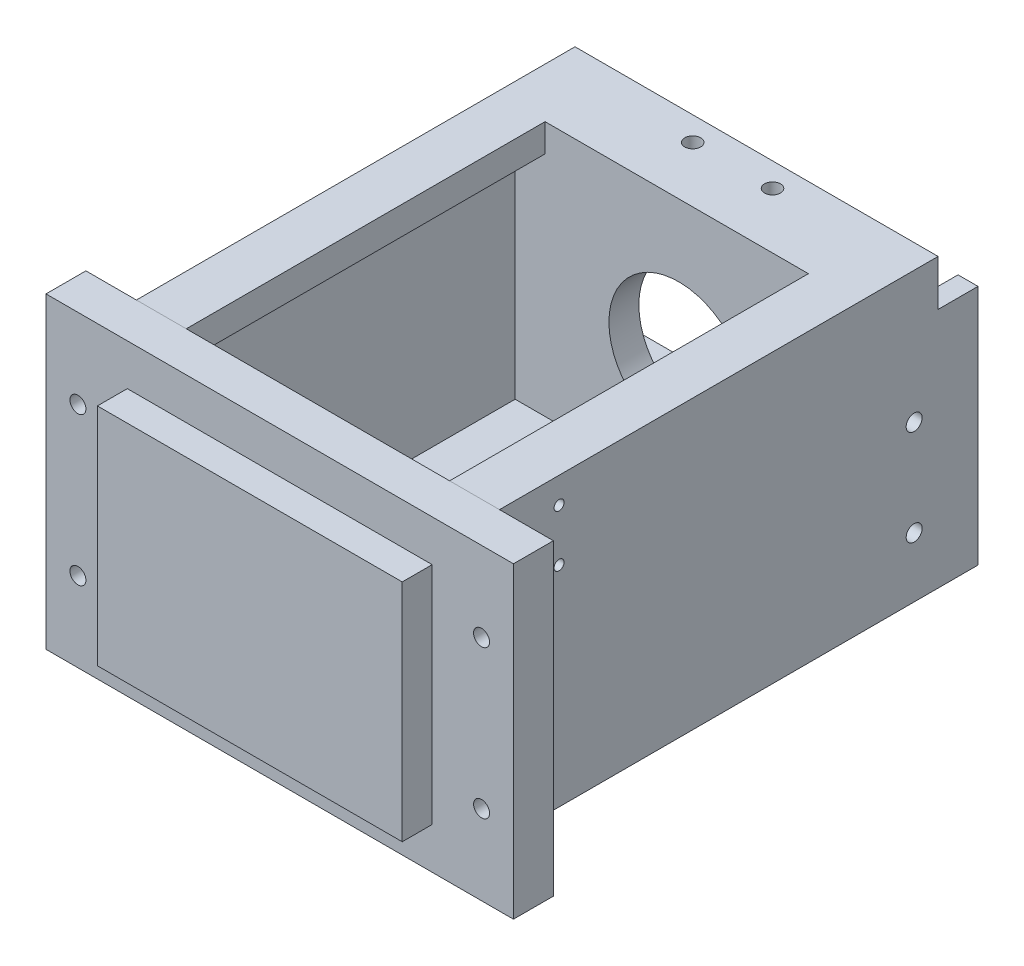
from build123d import *

# Parameters (mm, degrees)
SKETCH1_W               = 50
SKETCH1_H               = 51
BOSS_EXTRUDE1_DEPTH     = 3
SKETCH2_W               = 50
SKETCH2_H               = 3
BOSS_EXTRUDE2_DEPTH     = 50
FILLET1_R               = 2
CHAMFER1_SIZE           = 5
SKETCH4_R               = 12.55
SKETCH4_R_2             = 2.1
CUT_EXTRUDE2_DEPTH      = 50
BOSS_EXTRUDE3_DEPTH     = 3
CROQUIS1_W              = 117.155
CROQUIS1_H              = 77.15
SALIENTE_EXTRUIR1_DEPTH = 10
CROQUIS2_W              = 76.4
CROQUIS2_H              = 56.4
SALIENTE_EXTRUIR2_DEPTH = 7.5
CROQUIS3_R              = 2
CORTAR_EXTRUIR1_DEPTH   = 27.5
CROQUIS4_W              = 91
CROQUIS4_H              = 72
CROQUIS4_W_2            = 79
CROQUIS4_H_2            = 57
SALIENTE_EXTRUIR3_DEPTH = 120
CUT_EXTRUDE1_DEPTH      = 50
CROQUIS5_W              = 66
CROQUIS5_H              = 90
CORTAR_EXTRUIR2_DEPTH   = 64
CROQUIS7_R              = 2.1
CORTAR_EXTRUIR3_DEPTH   = 20
CROQUIS9_R              = 2
CORTAR_EXTRUIR5_DEPTH   = 110
CROQUIS8_R              = 2
CORTAR_EXTRUIR6_DEPTH   = 120
CROQUIS10_R             = 17.5
SALIENTE_EXTRUIR4_DEPTH = 7.5
CROQUIS11_W             = 81
CROQUIS11_H             = 10
CROQUIS11_W_2           = 5
CORTAR_EXTRUIR7_DEPTH   = 7.9
CROQUIS12_W             = 79
CROQUIS12_H             = 4.5
SALIENTE_EXTRUIR5_DEPTH = 12.5
CROQUIS14_W             = 10
CROQUIS14_H             = 3.6
CORTAR_EXTRUIR8_DEPTH   = 100
CROQUIS21_R             = 1.25
CORTAR_EXTRUIR10_DEPTH  = 4
CROQUIS22_R             = 1.5
CORTAR_EXTRUIR11_DEPTH  = 40
CROQUIS23_W             = 10
CROQUIS23_H             = 10
CORTAR_EXTRUIR12_DEPTH  = 10
CROQUIS24_W             = 2
CROQUIS24_H             = 52.5
CORTAR_EXTRUIR13_DEPTH  = 22.5


with BuildPart() as part:
    # Sketch1 → Boss-Extrude1 (new body)
    with BuildSketch(Plane.XY):
        Rectangle(SKETCH1_W, SKETCH1_H)
    extrude(amount=BOSS_EXTRUDE1_DEPTH)

    # Sketch2 → Boss-Extrude2 (add)
    with BuildSketch(Plane.XY.offset(3)):
        with Locations((0, -24)):
            Rectangle(SKETCH2_W, SKETCH2_H)
    extrude(amount=BOSS_EXTRUDE2_DEPTH)

    # Fillet1
    fillet1_edges = [part.edges().sort_by_distance(p)[0] for p in [
        (0, -22.5, 3),
        (0, -25.5, 0),
    ]]
    fillet(fillet1_edges, radius=FILLET1_R)

    # Chamfer1
    chamfer1_edges = [part.edges().sort_by_distance(p)[0] for p in [
        (-25, -24, 53),
        (25, -24, 53),
        (-25, 25.5, 1.5),
        (25, 25.5, 1.5),
    ]]
    chamfer(chamfer1_edges, length=CHAMFER1_SIZE)

    # Sketch4 → Cut-Extrude2 (cut)
    with BuildSketch(Plane.XY.offset(3)):
        with Locations((0, 4.5)):
            Circle(SKETCH4_R)
        with Locations((0, 22)):
            Circle(SKETCH4_R_2)
        with Locations((0, -13)):
            Circle(SKETCH4_R_2)
        with Locations((17.5, 4.5)):
            Circle(SKETCH4_R_2)
        with Locations((-17.5, 4.5)):
            Circle(SKETCH4_R_2)
    extrude(amount=-CUT_EXTRUDE2_DEPTH, mode=Mode.SUBTRACT)

    # Sketch5 → Boss-Extrude3 (add)
    with BuildSketch(Plane.ZY.offset(25)):
        with BuildLine():
            Line((3, -2.5), (16, -22.5))
            Line((16, -22.5), (5, -22.5))
            ThreePointArc((5, -22.5), (3.585786438, -21.914213562), (3, -20.5))
            Line((3, -20.5), (3, -2.5))
        make_face()
    boss_extrude3 = extrude(amount=-BOSS_EXTRUDE3_DEPTH)

    # Mirror1: Boss-Extrude3 across plane
    add(boss_extrude3.mirror(Plane(origin=(0, 0, 0), x_dir=(0, 0, 1), z_dir=(1, 0, 0))))



with BuildPart() as body_2:
    # Croquis1 → Saliente-Extruir1 (new body)
    with BuildSketch(Plane(origin=(0, 0, 55), x_dir=(-1, 0, 0), z_dir=(0, 0, -1))):
        with Locations((0.0025, 0)):
            Rectangle(CROQUIS1_W, CROQUIS1_H)
    extrude(amount=-SALIENTE_EXTRUIR1_DEPTH)

    # Croquis2 → Saliente-Extruir2 (add)
    with BuildSketch(Plane.XY.offset(65)):
        Rectangle(CROQUIS2_W, CROQUIS2_H)
    extrude(amount=SALIENTE_EXTRUIR2_DEPTH)

    # Croquis3 → Cortar-Extruir1 (cut)
    with BuildSketch(Plane(origin=(0, 0, 55), x_dir=(-1, 0, 0), z_dir=(0, 0, -1))):
        with Locations((50.58, -18.575)):
            Circle(CROQUIS3_R)
        with Locations((50.58, 18.575)):
            Circle(CROQUIS3_R)
    cortar_extruir1 = extrude(amount=-CORTAR_EXTRUIR1_DEPTH, mode=Mode.SUBTRACT)

    # Simetría1: Cortar-Extruir1 across plane
    add(cortar_extruir1.mirror(Plane(origin=(0, 0, 0), x_dir=(0, 0, 1), z_dir=(1, 0, 0))), mode=Mode.SUBTRACT)


with BuildPart() as part_1:
    add(part.part)

    add(body_2.part)  # Saliente-Extruir3 merges body 2
    # Croquis4 → Saliente-Extruir3 (add)
    with BuildSketch(Plane(origin=(0, 0, 55), x_dir=(-1, 0, 0), z_dir=(0, 0, -1))):
        with Locations((0.5, 2.5)):
            Rectangle(CROQUIS4_W, CROQUIS4_H)
        with Locations((1.5, 3)):
            Rectangle(CROQUIS4_W_2, CROQUIS4_H_2, mode=Mode.SUBTRACT)
    extrude(amount=SALIENTE_EXTRUIR3_DEPTH)

    # Sketch3 → Cut-Extrude1 (cut)
    with BuildSketch(Plane(origin=(0, -22.5, 0), x_dir=(1, 0, 0), z_dir=(0, 1, 0))):
        with BuildLine():
            Line((-17.1, -38), (-17.1, -37.9))
            ThreePointArc((-17.1, -37.9), (-15, -35.8), (-12.9, -37.9))
            Line((-12.9, -37.9), (-12.9, -38))
            ThreePointArc((-12.9, -38), (-15, -40.1), (-17.1, -38))
        make_face()
        with BuildLine():
            Line((12.9, -38), (12.9, -37.9))
            ThreePointArc((12.9, -37.9), (15, -35.8), (17.1, -37.9))
            Line((17.1, -37.9), (17.1, -38))
            ThreePointArc((17.1, -38), (15, -40.1), (12.9, -38))
        make_face()
    extrude(amount=-CUT_EXTRUDE1_DEPTH, mode=Mode.SUBTRACT)

    # Croquis5 → Cortar-Extruir2 (cut)
    with BuildSketch(Plane(origin=(0, 38.5, 0), x_dir=(1, 0, 0), z_dir=(0, 1, 0))):
        with Locations((-0.5, -10)):
            Rectangle(CROQUIS5_W, CROQUIS5_H)
    extrude(amount=-CORTAR_EXTRUIR2_DEPTH, mode=Mode.SUBTRACT)

    # Croquis7 → Cortar-Extruir3 (cut)
    with BuildSketch(Plane.XZ.offset(33.5)):
        with Locations((15, 19.753839811)):
            Circle(CROQUIS7_R)
        with Locations((-15, 19.753839811)):
            Circle(CROQUIS7_R)
    extrude(amount=-CORTAR_EXTRUIR3_DEPTH, mode=Mode.SUBTRACT)

    # Croquis9 → Cortar-Extruir5 (cut)
    with BuildSketch(Plane.ZY.offset(46)):
        with Locations((-49, -18.5)):
            Circle(CROQUIS9_R)
        with Locations((-49, 5.5)):
            Circle(CROQUIS9_R)
    extrude(amount=-CORTAR_EXTRUIR5_DEPTH, mode=Mode.SUBTRACT)

    # Croquis8 → Cortar-Extruir6 (cut)
    with BuildSketch(Plane(origin=(0, 38.5, 0), x_dir=(1, 0, 0), z_dir=(0, 1, 0))):
        with Locations((-10.5, 49)):
            Circle(CROQUIS8_R)
        with Locations((9.5, 49)):
            Circle(CROQUIS8_R)
    extrude(amount=-CORTAR_EXTRUIR6_DEPTH, mode=Mode.SUBTRACT)

    # Croquis10 → Saliente-Extruir4 (add)
    with BuildSketch(Plane(origin=(0, 0, -35), x_dir=(-1, 0, 0), z_dir=(0, 0, -1))):
        Polygon((41, 0), (41, -25.5), (-40, -25.5), (-40, 31.5), (41, 31.5), align=None)
        with Locations((0, 3)):
            Circle(CROQUIS10_R, mode=Mode.SUBTRACT)
    extrude(amount=SALIENTE_EXTRUIR4_DEPTH)

    # Croquis11 → Cortar-Extruir7 (cut)
    with BuildSketch(Plane(origin=(0, 38.5, 0), x_dir=(1, 0, 0), z_dir=(0, 1, 0))):
        with Locations((-0.5, 60)):
            Rectangle(CROQUIS11_W, CROQUIS11_H)
        with Locations((-43.5, 60)):
            Rectangle(CROQUIS11_W_2, CROQUIS11_H)
        with Locations((42.5, 60)):
            Rectangle(CROQUIS11_W_2, CROQUIS11_H)
    extrude(amount=-CORTAR_EXTRUIR7_DEPTH, mode=Mode.SUBTRACT)

    # Croquis12 → Saliente-Extruir5 (add)
    with BuildSketch(Plane(origin=(0, 0, -42.5), x_dir=(-1, 0, 0), z_dir=(0, 0, -1))):
        with Locations((1.5, 29.25)):
            Rectangle(CROQUIS12_W, CROQUIS12_H)
    extrude(amount=SALIENTE_EXTRUIR5_DEPTH)

    # Croquis14 → Cortar-Extruir8 (cut)
    with BuildSketch(Plane(origin=(45, 0, 0), x_dir=(0, 0, -1), z_dir=(1, 0, 0))):
        with Locations((60, 28.8)):
            Rectangle(CROQUIS14_W, CROQUIS14_H)
    extrude(amount=-CORTAR_EXTRUIR8_DEPTH, mode=Mode.SUBTRACT)

    # Croquis21 → Cortar-Extruir10 (cut)
    with BuildSketch(Plane(origin=(45, 0, 0), x_dir=(0, 0, -1), z_dir=(1, 0, 0))):
        with Locations((-40, 32)):
            Circle(CROQUIS21_R)
        with Locations((-40, 19)):
            Circle(CROQUIS21_R)
    extrude(amount=-CORTAR_EXTRUIR10_DEPTH, mode=Mode.SUBTRACT)

    # Croquis22 → Cortar-Extruir11 (cut)
    with BuildSketch(Plane.XZ.offset(33.5)):
        with Locations((30, -30)):
            Circle(CROQUIS22_R)
        with Locations((30, -20)):
            Circle(CROQUIS22_R)
    extrude(amount=-CORTAR_EXTRUIR11_DEPTH, mode=Mode.SUBTRACT)

    # Croquis23 → Cortar-Extruir12 (cut)
    with BuildSketch(Plane.ZY.offset(46)):
        with Locations((50, 8.5)):
            Rectangle(CROQUIS23_W, CROQUIS23_H)
    extrude(amount=-CORTAR_EXTRUIR12_DEPTH, mode=Mode.SUBTRACT)

    # Croquis24 → Cortar-Extruir13 (cut)
    with BuildSketch(Plane(origin=(0, 0, -65), x_dir=(-1, 0, 0), z_dir=(0, 0, -1))):
        with Locations((-39, 0.75)):
            Rectangle(CROQUIS24_W, CROQUIS24_H)
    extrude(amount=-CORTAR_EXTRUIR13_DEPTH, mode=Mode.SUBTRACT)


solid = part_1.part
